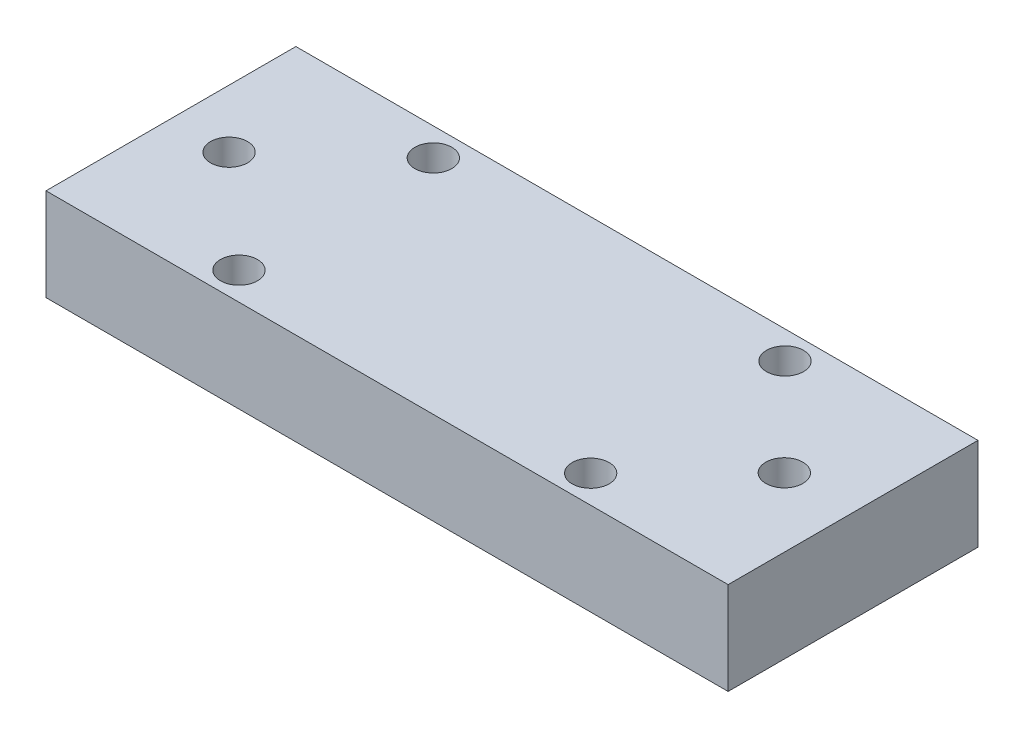
from build123d import *

# Parameters (mm, degrees)
SKETCH1_W           = 36.852824564
SKETCH1_H           = 13.5
SKETCH1_R           = 1
BOSS_EXTRUDE1_DEPTH = 5


with BuildPart() as part:
    # Sketch1 → Boss-Extrude1 (new body)
    with BuildSketch(Plane(origin=(0, 0, 0), x_dir=(1, 0, 0), z_dir=(0, 1, 0))):
        Rectangle(SKETCH1_W, SKETCH1_H)
        with Locations((-15.28648496, 0)):
            Circle(SKETCH1_R, mode=Mode.SUBTRACT)
        with Locations((14.71351504, 0)):
            Circle(SKETCH1_R, mode=Mode.SUBTRACT)
        with Locations((-9.5, 5.25)):
            Circle(SKETCH1_R, mode=Mode.SUBTRACT)
        with Locations((9.5, 5.25)):
            Circle(SKETCH1_R, mode=Mode.SUBTRACT)
        with Locations((9.5, -5.25)):
            Circle(SKETCH1_R, mode=Mode.SUBTRACT)
        with Locations((-9.5, -5.25)):
            Circle(SKETCH1_R, mode=Mode.SUBTRACT)
    extrude(amount=BOSS_EXTRUDE1_DEPTH)


solid = part.part
